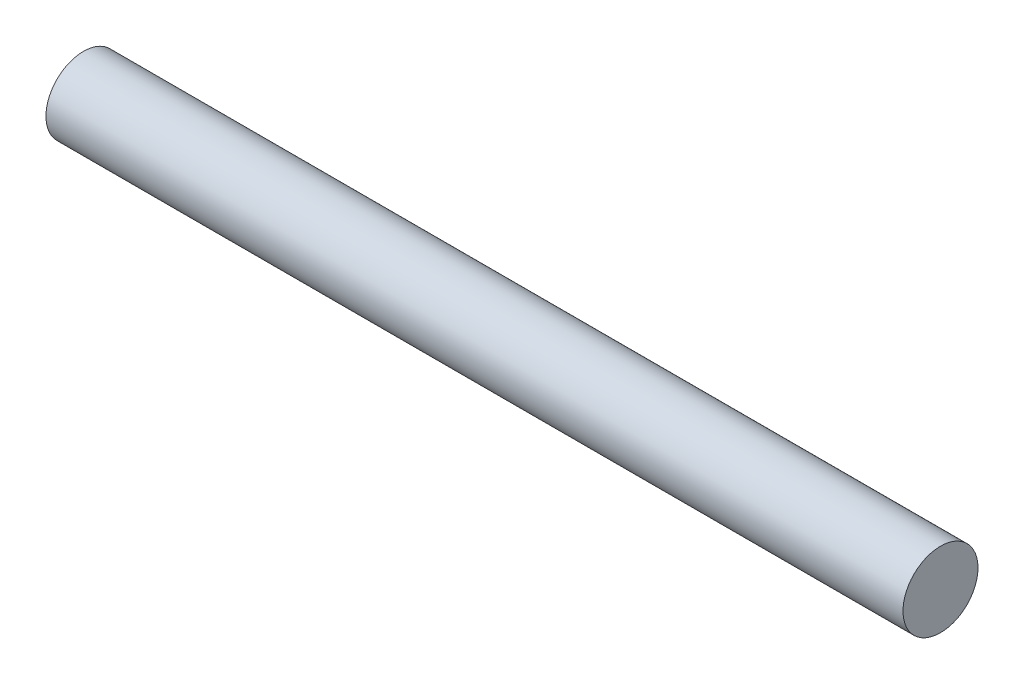
from build123d import *

# Parameters (mm, degrees)
SKETCH1_R           = 3
BOSS_EXTRUDE1_DEPTH = 68.55


with BuildPart() as part:
    # Sketch1 → Boss-Extrude1 (new body)
    with BuildSketch(Plane(origin=(0, 0, 0), x_dir=(0, 0, -1), z_dir=(1, 0, 0))):
        Circle(SKETCH1_R)
    extrude(amount=BOSS_EXTRUDE1_DEPTH)


solid = part.part
